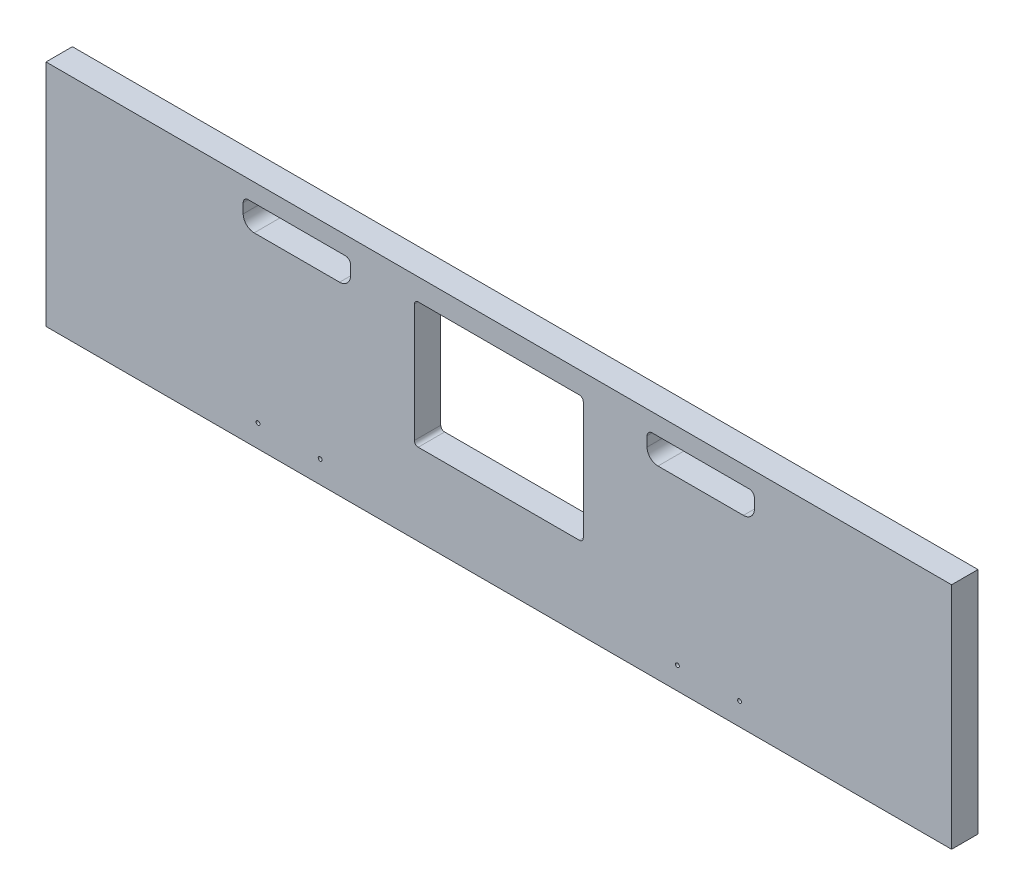
from build123d import *

# Parameters (mm, degrees)
SKETCH2_W          = 740.41
SKETCH2_H          = 187.325
EXTRUDE1_DEPTH     = 21.59
SKETCH3_R          = 1.5875
CUT_EXTRUDE1_DEPTH = 21.59


with BuildPart() as part:
    # Sketch2 → Extrude1 (new body)
    with BuildSketch(Plane.XY):
        with Locations((-233.045, -5408.6125)):
            Rectangle(SKETCH2_W, SKETCH2_H)
    extrude(amount=-EXTRUDE1_DEPTH)

    # Sketch3 → Cut-Extrude1 (cut)
    with BuildSketch(Plane.XY):
        with Locations((-429.895, -5484.0124)):
            Circle(SKETCH3_R)
        with Locations((-379.095, -5484.0124)):
            Circle(SKETCH3_R)
        with Locations((-86.995, -5484.0124)):
            Circle(SKETCH3_R)
        with Locations((-36.195, -5484.0124)):
            Circle(SKETCH3_R)
        with BuildLine():
            Line((-302.10125, -5335.905), (-302.10125, -5432.425))
            ThreePointArc((-302.10125, -5432.425), (-301.17131403, -5434.67006403), (-298.92625, -5435.6))
            Line((-298.92625, -5435.6), (-167.16375, -5435.6))
            ThreePointArc((-167.16375, -5435.6), (-164.91868597, -5434.67006403), (-163.98875, -5432.425))
            Line((-163.98875, -5432.425), (-163.98875, -5335.905))
            ThreePointArc((-163.98875, -5335.905), (-164.91868597, -5333.65993597), (-167.16375, -5332.73))
            Line((-167.16375, -5332.73), (-298.92625, -5332.73))
            ThreePointArc((-298.92625, -5332.73), (-301.17131403, -5333.65993597), (-302.10125, -5335.905))
        make_face()
        with BuildLine():
            Line((-354.2665, -5334), (-354.2665, -5341.9375))
            ThreePointArc((-354.2665, -5341.9375), (-356.888919435, -5348.268580565), (-363.22, -5350.891))
            Line((-363.22, -5350.891), (-433.07, -5350.891))
            ThreePointArc((-433.07, -5350.891), (-439.401080565, -5348.268580565), (-442.0235, -5341.9375))
            Line((-442.0235, -5341.9375), (-442.0235, -5334))
            ThreePointArc((-442.0235, -5334), (-440.79598452, -5331.03651548), (-437.8325, -5329.809))
            Line((-437.8325, -5329.809), (-358.4575, -5329.809))
            ThreePointArc((-358.4575, -5329.809), (-355.49401548, -5331.03651548), (-354.2665, -5334))
        make_face()
        with BuildLine():
            Line((-102.87, -5350.891), (-33.02, -5350.891))
            ThreePointArc((-33.02, -5350.891), (-26.688919435, -5348.268580565), (-24.0665, -5341.9375))
            Line((-24.0665, -5341.9375), (-24.0665, -5334))
            ThreePointArc((-24.0665, -5334), (-25.29401548, -5331.03651548), (-28.2575, -5329.809))
            Line((-28.2575, -5329.809), (-107.6325, -5329.809))
            ThreePointArc((-107.6325, -5329.809), (-110.59598452, -5331.03651548), (-111.8235, -5334))
            Line((-111.8235, -5334), (-111.8235, -5341.9375))
            ThreePointArc((-111.8235, -5341.9375), (-109.201080565, -5348.268580565), (-102.87, -5350.891))
        make_face()
    extrude(amount=-CUT_EXTRUDE1_DEPTH, mode=Mode.SUBTRACT)


solid = part.part
